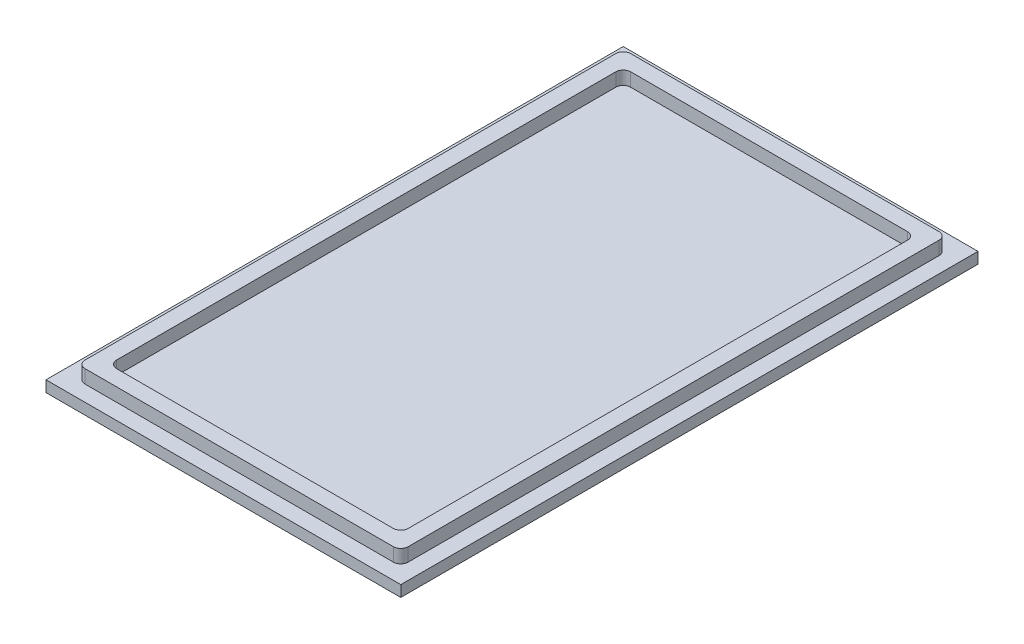
from build123d import *

# Parameters (mm, degrees)
PCB_DIMENSIONS_W    = 47.716732244
PCB_DIMENSIONS_H    = 77.636732244
BOSS_EXTRUDE3_DEPTH = 1.5
SKETCH5_W           = 43.474091557
SKETCH5_H           = 73.394091557
SKETCH5_W_2         = 39.23145087
SKETCH5_H_2         = 69.15145087
BOSS_EXTRUDE4_DEPTH = 1.8
FILLET1_R           = 1
SKETCH6_W           = 12
SKETCH6_H           = 31.966906412
SKETCH6_H_2         = 32.033093588
BOSS_EXTRUDE5_DEPTH = 10
SKETCH7_W           = 48
SKETCH7_H           = 6
CUT_EXTRUDE1_DEPTH  = 24
FILLET2_R           = 6
FILLET3_R           = 1
SCALE1_SCALE        = 0.99


with BuildPart() as part:
    # PCB Dimensions → Boss-Extrude3 (new body)
    with BuildSketch(Plane(origin=(0, 0, 0), x_dir=(1, 0, 0), z_dir=(0, 1, 0))):
        with Locations((20.322832216, -35.282832216)):
            Rectangle(PCB_DIMENSIONS_W, PCB_DIMENSIONS_H)
    extrude(amount=BOSS_EXTRUDE3_DEPTH)

    # Sketch5 → Boss-Extrude4 (add)
    with BuildSketch(Plane(origin=(0, 1.5, 0), x_dir=(1, 0, 0), z_dir=(0, 1, 0))):
        with Locations((20.322832217, -35.282832217)):
            Rectangle(SKETCH5_W, SKETCH5_H)
        with Locations((20.322832216, -35.282832216)):
            Rectangle(SKETCH5_W_2, SKETCH5_H_2, mode=Mode.SUBTRACT)
    extrude(amount=BOSS_EXTRUDE4_DEPTH)

    # Fillet1
    fillet1_edges = [part.edges().sort_by_distance(p)[0] for p in [
        (-1.414213562, 2.4, -1.414213562),
        (-1.414213562, 2.4, 71.979877995),
        (42.059877995, 2.4, 71.979877995),
        (42.059877995, 2.4, -1.414213562),
        (0.707106781, 2.4, 0.707106781),
        (0.707106781, 2.4, 69.858557651),
        (39.938557651, 2.4, 69.858557651),
        (39.938557651, 2.4, 0.707106781),
    ]]
    fillet(fillet1_edges, radius=FILLET1_R)

    # Sketch6 → Boss-Extrude5 (add)
    with BuildSketch(Plane.XZ):
        with Locations((14.322832216, 51.266285422)):
            Rectangle(SKETCH6_W, SKETCH6_H)
        with Locations((26.322832216, 51.266285422)):
            Rectangle(SKETCH6_W, SKETCH6_H)
        with Locations((14.322832216, 19.266285422)):
            Rectangle(SKETCH6_W, SKETCH6_H_2)
        with Locations((26.322832216, 19.266285422)):
            Rectangle(SKETCH6_W, SKETCH6_H_2)
    extrude(amount=BOSS_EXTRUDE5_DEPTH)

    # Sketch7 → Cut-Extrude1 (cut)
    with BuildSketch(Plane(origin=(32.322832216, 0, 0), x_dir=(0, 0, -1), z_dir=(1, 0, 0))):
        with Locations((-35.249738628, -3)):
            Rectangle(SKETCH7_W, SKETCH7_H)
    extrude(amount=-CUT_EXTRUDE1_DEPTH, mode=Mode.SUBTRACT)

    # Fillet2
    fillet2_edges = [part.edges().sort_by_distance(p)[0] for p in [
        (20.322832216, -10, 67.249738628),
        (20.322832216, -10, 3.249738628),
    ]]
    fillet(fillet2_edges, radius=FILLET2_R)

    # Fillet3
    fillet3_edges = [part.edges().sort_by_distance(p)[0] for p in [
        (20.322832216, -6, 59.249738628),
        (20.322832216, -6, 11.249738628),
    ]]
    fillet(fillet3_edges, radius=FILLET3_R)


with BuildPart() as part_1:
    # Scale1: scaled about (20.322832216, -3.218350849, 35.264379677)
    add(part.part.scale(SCALE1_SCALE).moved(Location((0.203228322, -0.032183508, 0.352643797))))


solid = part_1.part
